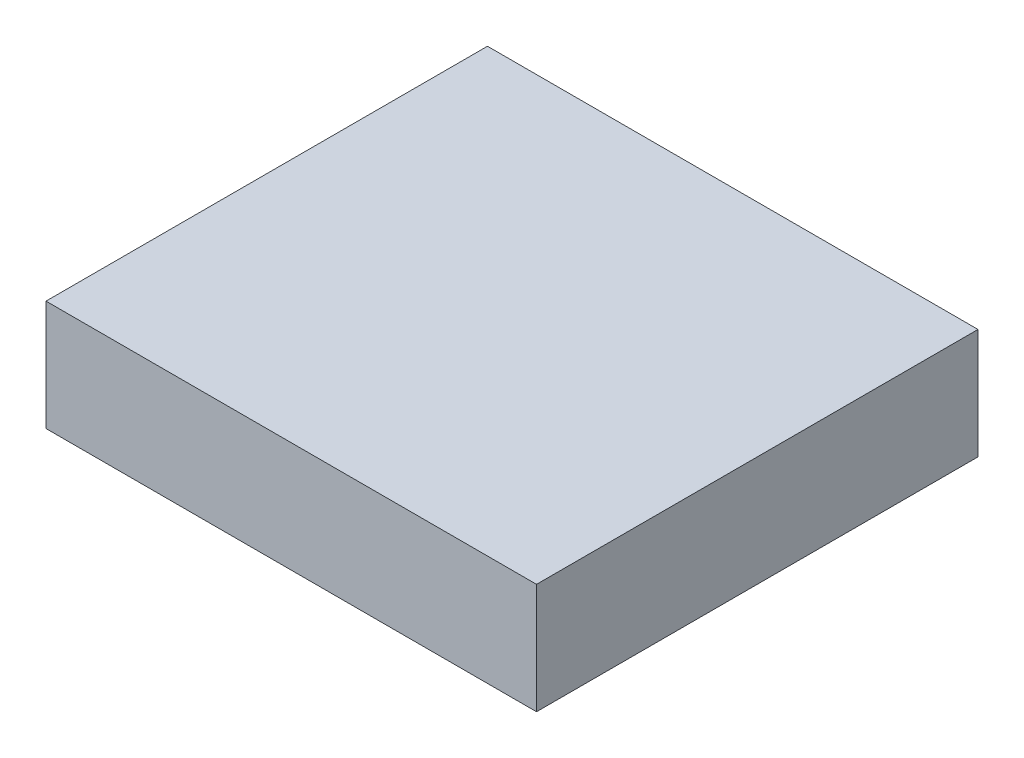
from build123d import *

# Parameters (mm, degrees)
SKETCH1_W           = 100
SKETCH1_H           = 90
BOSS_EXTRUDE1_DEPTH = 22.5


with BuildPart() as part:
    # Sketch1 → Boss-Extrude1 (new body)
    with BuildSketch(Plane(origin=(0, 0, 0), x_dir=(1, 0, 0), z_dir=(0, 1, 0))):
        with Locations((50, 45)):
            Rectangle(SKETCH1_W, SKETCH1_H)
    extrude(amount=BOSS_EXTRUDE1_DEPTH)


solid = part.part
